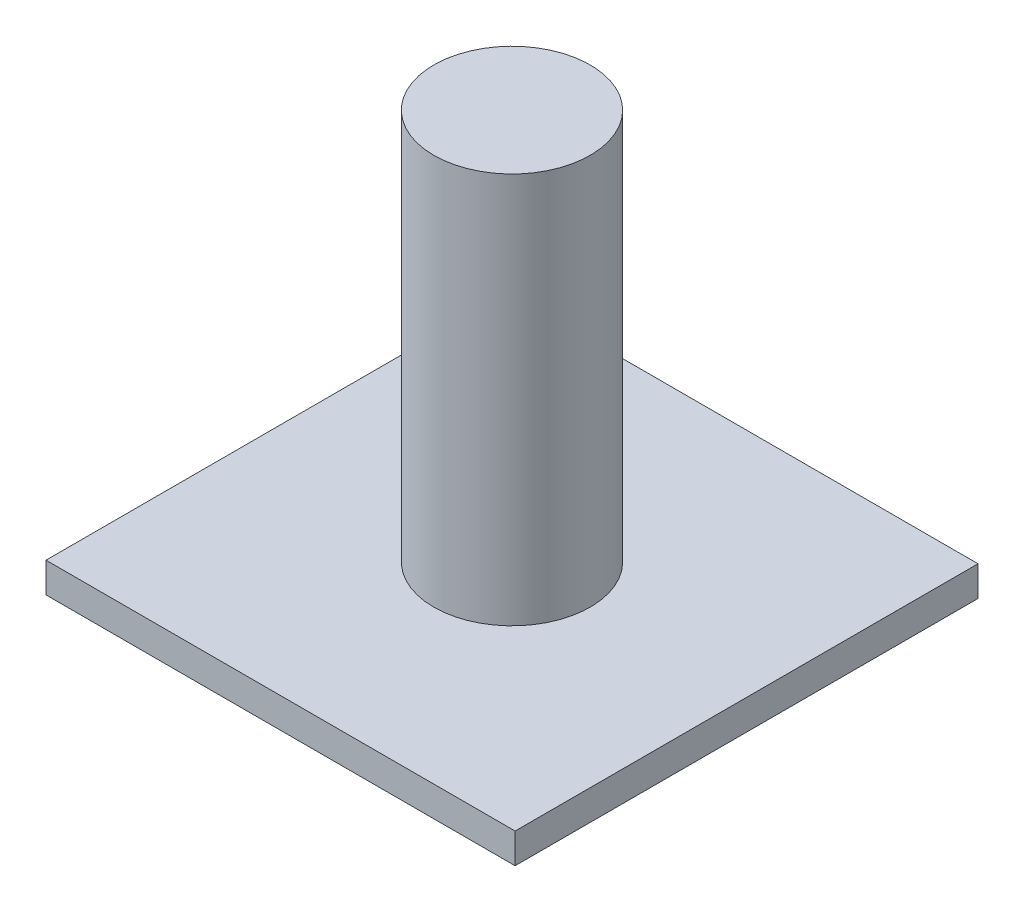
from build123d import *

# Parameters (mm, degrees)
SKETCH1_W           = 77.924354106
SKETCH1_H           = 76.892243456
BOSS_EXTRUDE1_DEPTH = 5
SKETCH2_R           = 13
BOSS_EXTRUDE2_DEPTH = 65


with BuildPart() as part:
    # Sketch1 → Boss-Extrude1 (new body)
    with BuildSketch(Plane(origin=(0, 0, 0), x_dir=(1, 0, 0), z_dir=(0, 1, 0))):
        Rectangle(SKETCH1_W, SKETCH1_H)
    extrude(amount=BOSS_EXTRUDE1_DEPTH)

    # Sketch2 → Boss-Extrude2 (add)
    with BuildSketch(Plane(origin=(0, 5, 0), x_dir=(1, 0, 0), z_dir=(0, 1, 0))):
        Circle(SKETCH2_R)
    extrude(amount=BOSS_EXTRUDE2_DEPTH)


solid = part.part
